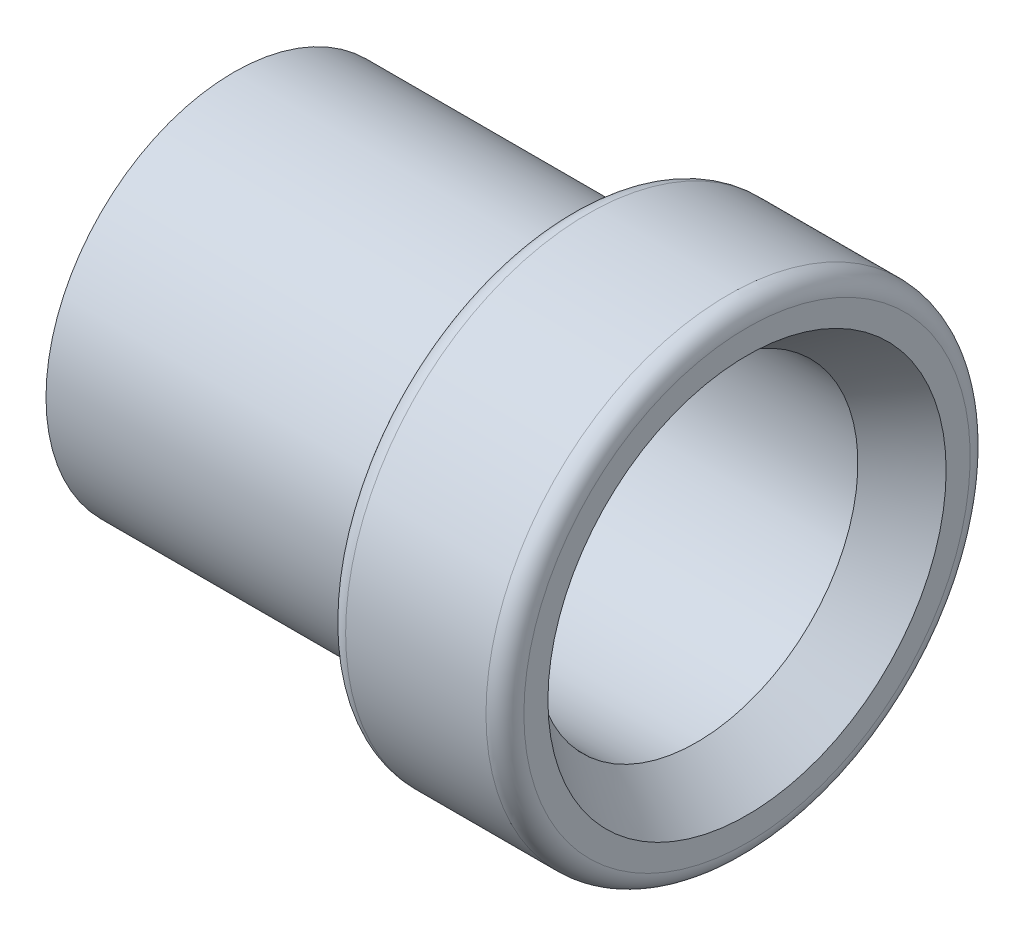
from build123d import *


with BuildPart() as part:
    # Sketch1 → Revolve1 (revolve)
    with BuildSketch(Plane.XY):
        with BuildLine():
            Line((-5.1562, 3.2385), (4.144991846, 3.2385))
            Line((4.144991846, 3.2385), (5.1562, 4.0005))
            Line((5.1562, 4.0005), (5.1562, 4.4831))
            ThreePointArc((5.1562, 4.4831), (5.044607684, 4.752507684), (4.7752, 4.8641))
            Line((4.7752, 4.8641), (1.9558, 4.8641))
            ThreePointArc((1.9558, 4.8641), (1.686392316, 4.752507684), (1.5748, 4.4831))
            Line((1.5748, 4.4831), (1.5748, 3.7719))
            Line((1.5748, 3.7719), (-5.1562, 3.7719))
            Line((-5.1562, 3.7719), (-5.1562, 3.2385))
        make_face()
    revolve(axis=Axis((-5.1562, 0, 0), (1, 0, 0)))


solid = part.part
